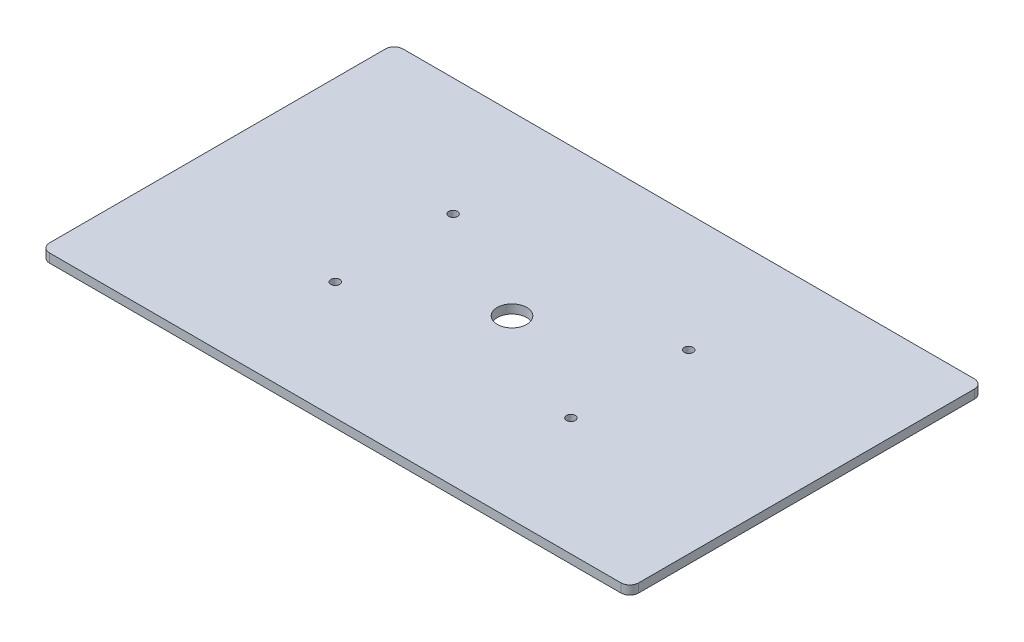
from build123d import *

# Parameters (mm, degrees)
SKETCH1_W               = 200
SKETCH1_H               = 120
BOSS_EXTRUDE1_DEPTH     = 3
FILLET1_R               = 3
SKETCH2_R               = 1.5
CUT_EXTRUDE1_DEPTH      = 3
MIRROR2_COPY_1_SKETCH_R = 1.5
MIRROR2_COPY_1_DEPTH    = 3
SKETCH3_R               = 5
CUT_EXTRUDE2_DEPTH      = 3


with BuildPart() as part:
    # Sketch1 → Boss-Extrude1 (new body)
    with BuildSketch(Plane(origin=(0, 0, 0), x_dir=(1, 0, 0), z_dir=(0, 1, 0))):
        Rectangle(SKETCH1_W, SKETCH1_H)
    extrude(amount=BOSS_EXTRUDE1_DEPTH)

    # Fillet1
    fillet1_edges = [part.edges().sort_by_distance(p)[0] for p in [
        (100, 1.5, 60),
        (-100, 1.5, 60),
        (-100, 1.5, -60),
        (100, 1.5, -60),
    ]]
    fillet(fillet1_edges, radius=FILLET1_R)

    # Sketch2 → Cut-Extrude1 (cut)
    with BuildSketch(Plane(origin=(0, 3, 0), x_dir=(1, 0, 0), z_dir=(0, 1, 0))):
        with Locations((40, 20)):
            Circle(SKETCH2_R)
    cut_extrude1 = extrude(amount=-CUT_EXTRUDE1_DEPTH, mode=Mode.SUBTRACT)

    # Mirror1: Cut-Extrude1 across plane
    add(cut_extrude1.mirror(Plane.XY), mode=Mode.SUBTRACT)

    # Mirror2: Cut-Extrude1 across plane
    add(cut_extrude1.mirror(Plane(origin=(0, 0, 0), x_dir=(0, 0, 1), z_dir=(1, 0, 0))), mode=Mode.SUBTRACT)

    # Mirror2 copy 1 sketch → Mirror2 copy 1 (cut)
    with BuildSketch(Plane(origin=(0, 3, 0), x_dir=(-1, 0, 0), z_dir=(0, 1, 0))):
        with Locations((40, 20)):
            Circle(MIRROR2_COPY_1_SKETCH_R)
    extrude(amount=-MIRROR2_COPY_1_DEPTH, mode=Mode.SUBTRACT)

    # Sketch3 → Cut-Extrude2 (cut)
    with BuildSketch(Plane(origin=(0, 3, 0), x_dir=(1, 0, 0), z_dir=(0, 1, 0))):
        Circle(SKETCH3_R)
    extrude(amount=-CUT_EXTRUDE2_DEPTH, mode=Mode.SUBTRACT)


solid = part.part
